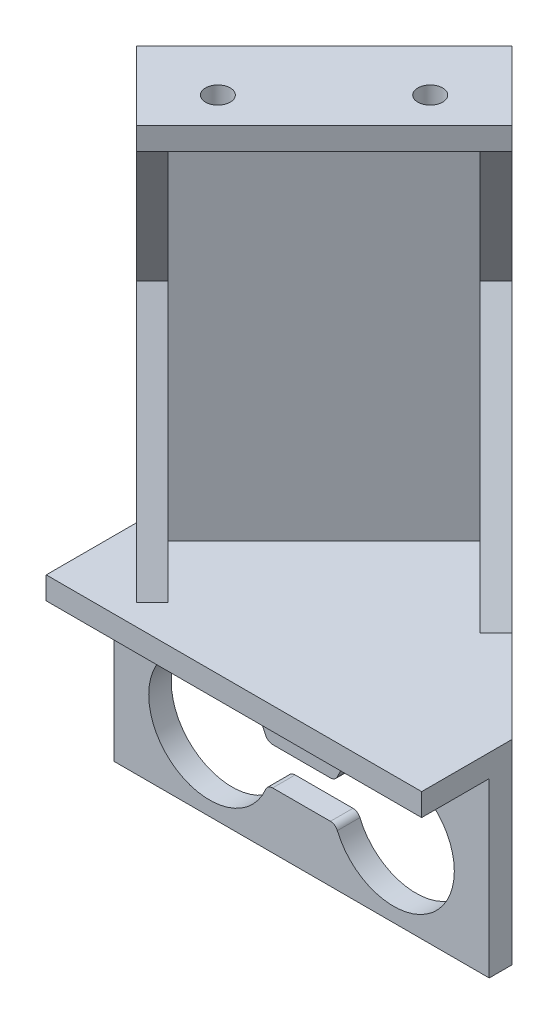
from build123d import *

# Parameters (mm, degrees)
SKETCH_1_W          = 50
SKETCH_1_H          = 20
EXTRUDE_1_DEPTH     = 3
SKETCH_2_W          = 50
SKETCH_2_H          = 12
EXTRUDE_2_DEPTH     = 6
SKETCH_5_W          = 50
SKETCH_5_H          = 9
CUT_EXTRUDE_2_DEPTH = 3
EXTRUDE_3_DEPTH     = 3
EXTRUDE_4_DEPTH     = 55
SKETCH_12_W         = 32.35533906
SKETCH_12_H         = 3
EXTRUDE_6_DEPTH     = 10
EXTRUDE_7_DEPTH     = 3
EXTRUDE_8_DEPTH     = 3
SKETCH_15_R         = 1.65
CUT_EXTRUDE_3_DEPTH = 3


with BuildPart() as part:
    # 草图1 → 凸台-拉伸1 (new body)
    with BuildSketch(Plane.XY):
        Rectangle(SKETCH_1_W, SKETCH_1_H)
        with BuildLine():
            Line((-3.85, 2.5), (3.85, 2.5))
            ThreePointArc((3.85, 2.5), (4.404700196, 2.667949706), (4.773076923, 3.115384615))
            ThreePointArc((4.773076923, 3.115384615), (20.35, 0), (4.773076923, -3.115384615))
            ThreePointArc((4.773076923, -3.115384615), (4.404700196, -2.667949706), (3.85, -2.5))
            Line((3.85, -2.5), (-3.85, -2.5))
            ThreePointArc((-3.85, -2.5), (-4.404700196, -2.667949706), (-4.773076923, -3.115384615))
            ThreePointArc((-4.773076923, -3.115384615), (-20.35, 0), (-4.773076923, 3.115384615))
            ThreePointArc((-4.773076923, 3.115384615), (-4.404700196, 2.667949706), (-3.85, 2.5))
        make_face(mode=Mode.SUBTRACT)
        with BuildLine():
            Line((3.25, 5.5), (-3.25, 5.5))
            ThreePointArc((-3.25, 5.5), (-5, 7.25), (-3.25, 9))
            Line((-3.25, 9), (3.25, 9))
            ThreePointArc((3.25, 9), (5, 7.25), (3.25, 5.5))
        make_face(mode=Mode.SUBTRACT)
    extrude(amount=EXTRUDE_1_DEPTH)

    # 草图2 → 凸台-拉伸2 (add)
    with BuildSketch(Plane(origin=(0, 10, 0), x_dir=(1, 0, 0), z_dir=(0, 1, 0))):
        with Locations((0, -6)):
            Rectangle(SKETCH_2_W, SKETCH_2_H)
    extrude(amount=EXTRUDE_2_DEPTH)

    # 草图5 → 切除-拉伸2 (cut)
    with BuildSketch(Plane.XZ.offset(-10)):
        with Locations((0, 7.5)):
            Rectangle(SKETCH_5_W, SKETCH_5_H)
    extrude(amount=-CUT_EXTRUDE_2_DEPTH, mode=Mode.SUBTRACT)

    # 草图9 → 凸台-拉伸3 (add)
    with BuildSketch(Plane(origin=(0, 16, 0), x_dir=(1, 0, 0), z_dir=(0, 1, 0))):
        Polygon((25, 0), (0, 25), (-25, 0), align=None)
    extrude(amount=-EXTRUDE_3_DEPTH)

    # 草图11 → 凸台-拉伸4 (add)
    with BuildSketch(Plane(origin=(0, 16, 0), x_dir=(1, 0, 0), z_dir=(0, 1, 0))):
        Polygon((0, 25), (2.121320344, 22.878679656), (-22.878679656, -2.121320344), (-25, 0), align=None)
    extrude(amount=EXTRUDE_4_DEPTH)

    # 草图12 → 凸台-拉伸6 (add)
    with BuildSketch(Plane(origin=(-10.378679656, 0, -10.378679656), x_dir=(0.707106781, 0, -0.707106781), z_dir=(0.707106781, 0, 0.707106781))):
        with Locations((-1.5, 69.5)):
            Rectangle(SKETCH_12_W, SKETCH_12_H)
    extrude(amount=EXTRUDE_6_DEPTH)

    # 草图13 → 凸台-拉伸7 (add)
    with BuildSketch(Plane(origin=(12.5, 0, -12.5), x_dir=(-0.707106781, 0, -0.707106781), z_dir=(0.707106781, 0, -0.707106781))):
        Polygon((14.67766953, 16), (14.67766953, 46), (-0.32233047, 16), align=None)
        Polygon((14.67766953, 46), (14.67766953, 71), (4.67766953, 71), (4.67766953, 68), align=None)
    extrude(amount=-EXTRUDE_7_DEPTH)

    # 草图14 → 凸台-拉伸8 (add)
    with BuildSketch(Plane(origin=(-12.5, 0, 12.5), x_dir=(0.707106781, 0, 0.707106781), z_dir=(-0.707106781, 0, 0.707106781))):
        Polygon((-14.67766953, 46), (-14.67766953, 16), (-4.67766953, 16), align=None)
        Polygon((-14.67766953, 68), (-14.67766953, 46), (-4.67766953, 68), align=None)
    extrude(amount=-EXTRUDE_8_DEPTH)

    # 草图15 → 切除-拉伸3 (cut)
    with BuildSketch(Plane.XZ.offset(-68)):
        with Locations((0.227922061, -13.914213562)):
            Circle(SKETCH_15_R)
        with Locations((-13.914213562, 0.227922061)):
            Circle(SKETCH_15_R)
    extrude(amount=-CUT_EXTRUDE_3_DEPTH, mode=Mode.SUBTRACT)


solid = part.part
